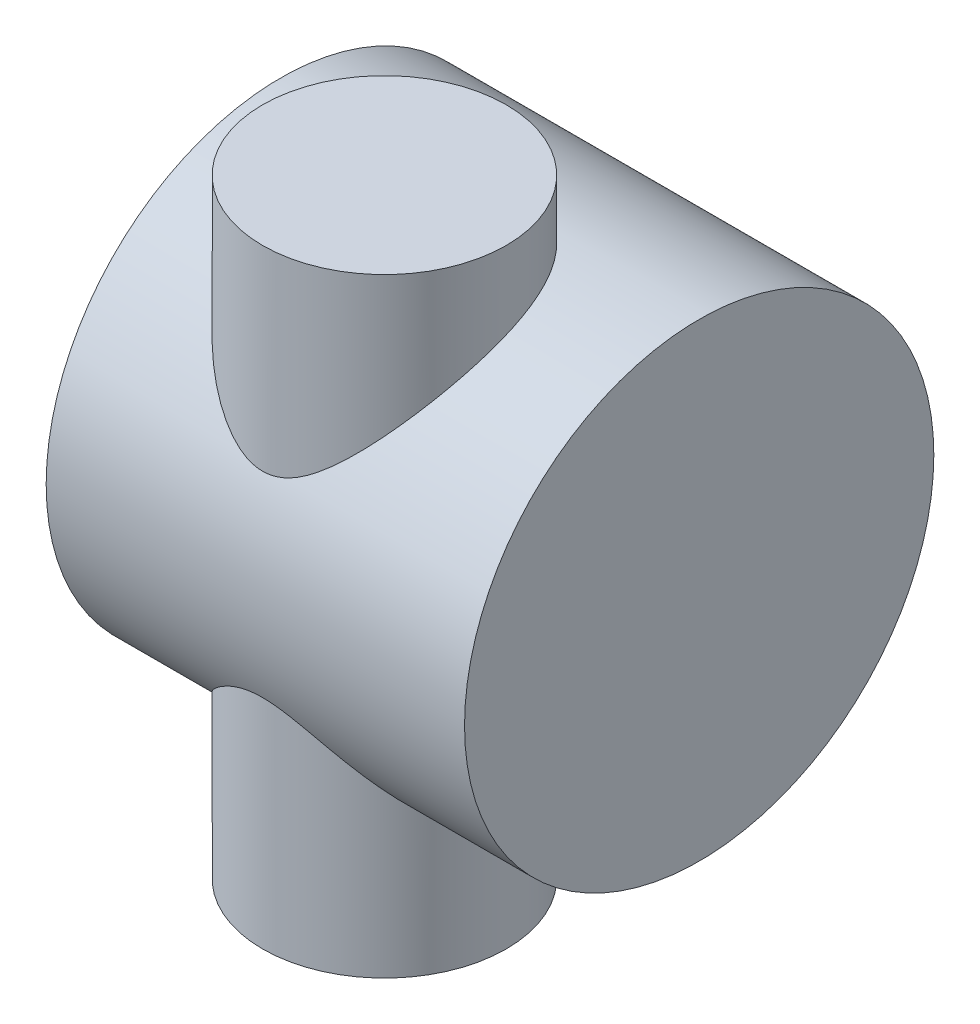
from build123d import *

# Parameters (mm, degrees)
SKETCH1_R                = 30
BOSS_EXTRUDE1_DEPTH      = 150
SKETCH3_R                = 57.769734486
BOSS_EXTRUDE2_DEPTH      = 25
BOSS_EXTRUDE2_DEPTH_BACK = 78


with BuildPart() as part:
    # Sketch1 → Boss-Extrude1 (new body)
    with BuildSketch(Plane(origin=(0, 0, 0), x_dir=(1, 0, 0), z_dir=(0, 1, 0))):
        Circle(SKETCH1_R)
    extrude(amount=BOSS_EXTRUDE1_DEPTH)

    # Sketch3 → Boss-Extrude2 (add, two sides)
    with BuildSketch(Plane(origin=(30, 0, 0), x_dir=(0, 0, -1), z_dir=(1, 0, 0))) as boss_extrude2_sk:
        with Locations((22.49423093, 77.731577971)):
            Circle(SKETCH3_R)
    extrude(amount=BOSS_EXTRUDE2_DEPTH)
    extrude(boss_extrude2_sk.sketch, amount=-BOSS_EXTRUDE2_DEPTH_BACK)


solid = part.part
